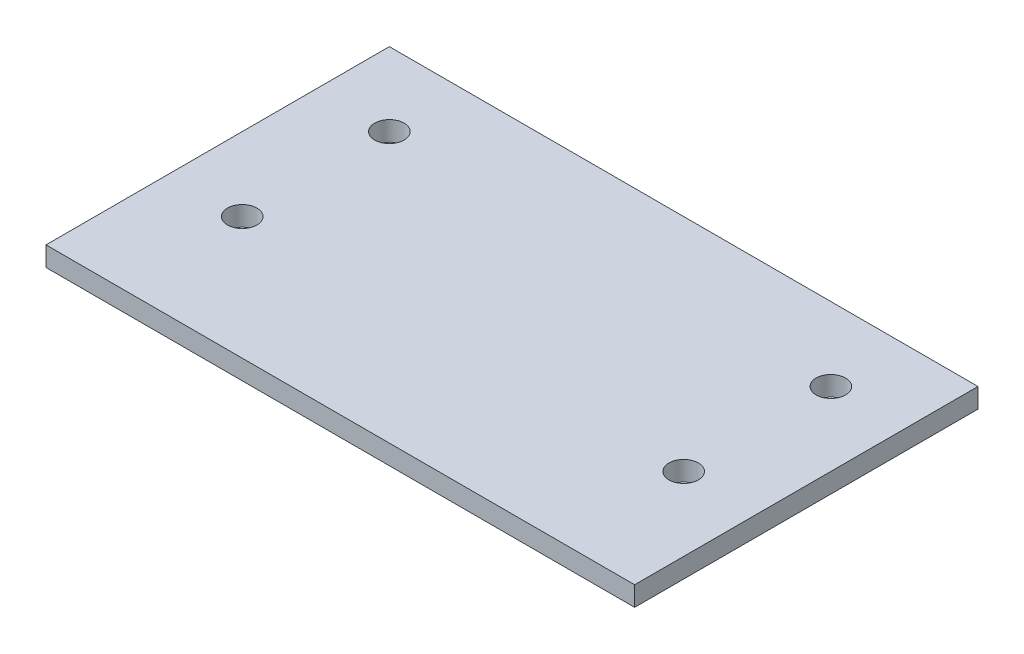
from build123d import *

# Parameters (mm, degrees)
CROQUIS1_W              = 60
CROQUIS1_H              = 35
SALIENTE_EXTRUIR1_DEPTH = 2
CORTAR_EXTRUIR1_REACH   = 4
CROQUIS2_R              = 1.5


with BuildPart() as part:
    # Croquis1 → Saliente-Extruir1 (new body)
    with BuildSketch(Plane(origin=(0, 0, 0), x_dir=(1, 0, 0), z_dir=(0, 1, 0))):
        Rectangle(CROQUIS1_W, CROQUIS1_H)
    extrude(amount=SALIENTE_EXTRUIR1_DEPTH)

    # Croquis2 → Cortar-Extruir1 (cut, up to next)
    with BuildSketch(Plane.XZ, mode=Mode.PRIVATE) as cortar_extruir1_sk1:
        with Locations((22.5, -10)):
            Circle(CROQUIS2_R)
    cortar_extruir1_tool1 = extrude(cortar_extruir1_sk1.sketch, amount=-CORTAR_EXTRUIR1_REACH, mode=Mode.PRIVATE) & part.part
    add(cortar_extruir1_tool1.solids().sort_by_distance((22.5, 0, -10))[0], mode=Mode.SUBTRACT)
    # Croquis2 → Cortar-Extruir1 (cut, up to next)
    with BuildSketch(Plane.XZ, mode=Mode.PRIVATE) as cortar_extruir1_sk2:
        with Locations((22.5, 5)):
            Circle(CROQUIS2_R)
    cortar_extruir1_tool2 = extrude(cortar_extruir1_sk2.sketch, amount=-CORTAR_EXTRUIR1_REACH, mode=Mode.PRIVATE) & part.part
    add(cortar_extruir1_tool2.solids().sort_by_distance((22.5, 0, 5))[0], mode=Mode.SUBTRACT)
    # Croquis2 → Cortar-Extruir1 (cut, up to next)
    with BuildSketch(Plane.XZ, mode=Mode.PRIVATE) as cortar_extruir1_sk3:
        with Locations((-22.5, -10)):
            Circle(CROQUIS2_R)
    cortar_extruir1_tool3 = extrude(cortar_extruir1_sk3.sketch, amount=-CORTAR_EXTRUIR1_REACH, mode=Mode.PRIVATE) & part.part
    add(cortar_extruir1_tool3.solids().sort_by_distance((-22.5, 0, -10))[0], mode=Mode.SUBTRACT)
    # Croquis2 → Cortar-Extruir1 (cut, up to next)
    with BuildSketch(Plane.XZ, mode=Mode.PRIVATE) as cortar_extruir1_sk4:
        with Locations((-22.5, 5)):
            Circle(CROQUIS2_R)
    cortar_extruir1_tool4 = extrude(cortar_extruir1_sk4.sketch, amount=-CORTAR_EXTRUIR1_REACH, mode=Mode.PRIVATE) & part.part
    add(cortar_extruir1_tool4.solids().sort_by_distance((-22.5, 0, 5))[0], mode=Mode.SUBTRACT)


solid = part.part
